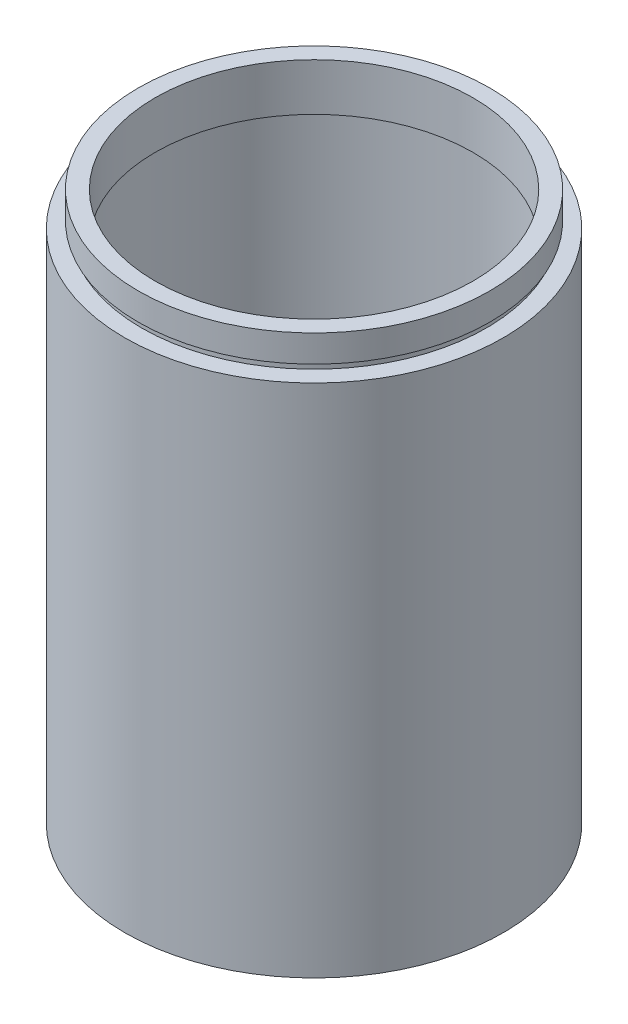
from build123d import *


with BuildPart() as part:
    # 草图1 → 旋转1 (revolve)
    with BuildSketch(Plane.XY, mode=Mode.PRIVATE) as revolve_1_sk:
        Polygon((23.5, 81.2), (26, 81.2), (26, 77.2), (25.5, 77.2), (25.5, 76.2), (28, 76.2), (28, 0), (25.5, 0), (25.5, 73.2), (26.1, 73.2), (26.1, 74.2), (23.5, 74.2), align=None)
    revolve(revolve_1_sk.sketch.rotate(Axis((0, 161.376166943, 0), (0, -1, 0)), 90), axis=Axis((0, 161.376166943, 0), (0, -1, 0)))  # turned: the seam where the file's is


solid = part.part
